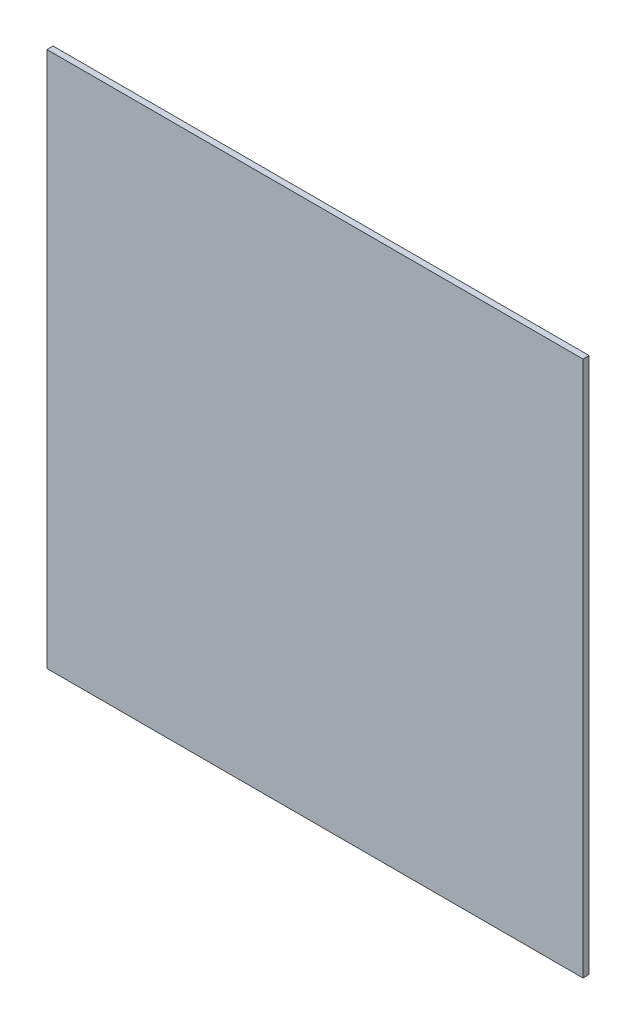
from build123d import *

# Parameters (mm, degrees)
ESQUISSE1_W        = 220
ESQUISSE1_H        = 220
BOSS_EXTRU_1_DEPTH = 2.5


with BuildPart() as part:
    # Esquisse1 → Boss.-Extru.1 (new body)
    with BuildSketch(Plane.XY):
        with Locations((110, 110)):
            Rectangle(ESQUISSE1_W, ESQUISSE1_H)
    extrude(amount=BOSS_EXTRU_1_DEPTH)


solid = part.part
